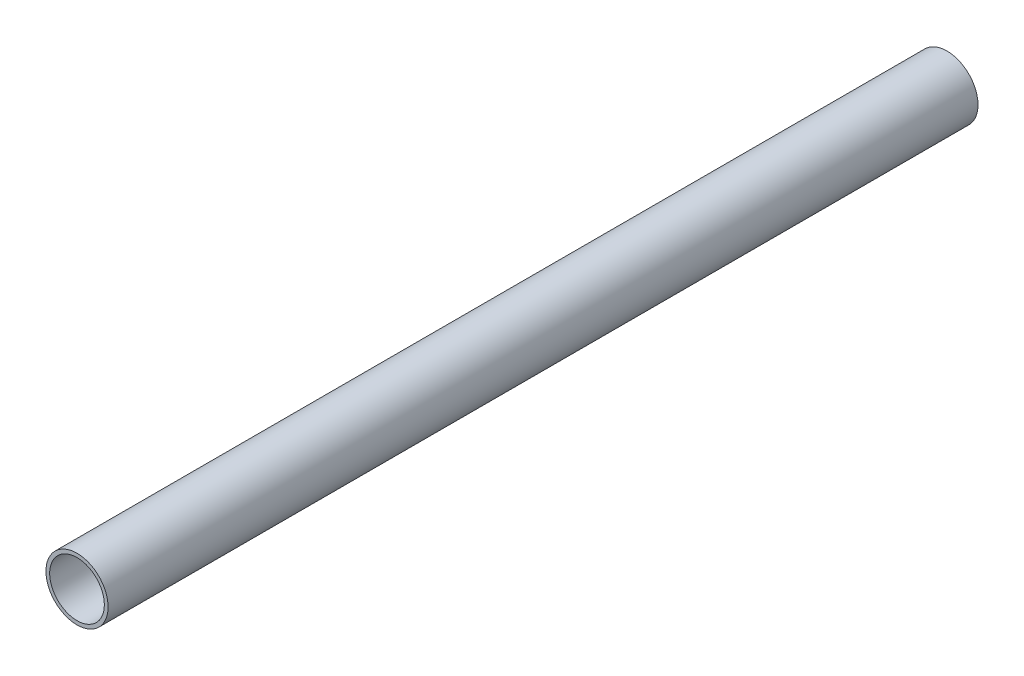
from build123d import *

# Parameters (mm, degrees)
SKETCH1_R           = 12.5
SKETCH1_R_2         = 11
BOSS_EXTRUDE1_DEPTH = 350


with BuildPart() as part:
    # Sketch1 → Boss-Extrude1 (new body)
    with BuildSketch(Plane.XY):
        Circle(SKETCH1_R)
        Circle(SKETCH1_R_2, mode=Mode.SUBTRACT)
    extrude(amount=BOSS_EXTRUDE1_DEPTH)


solid = part.part
